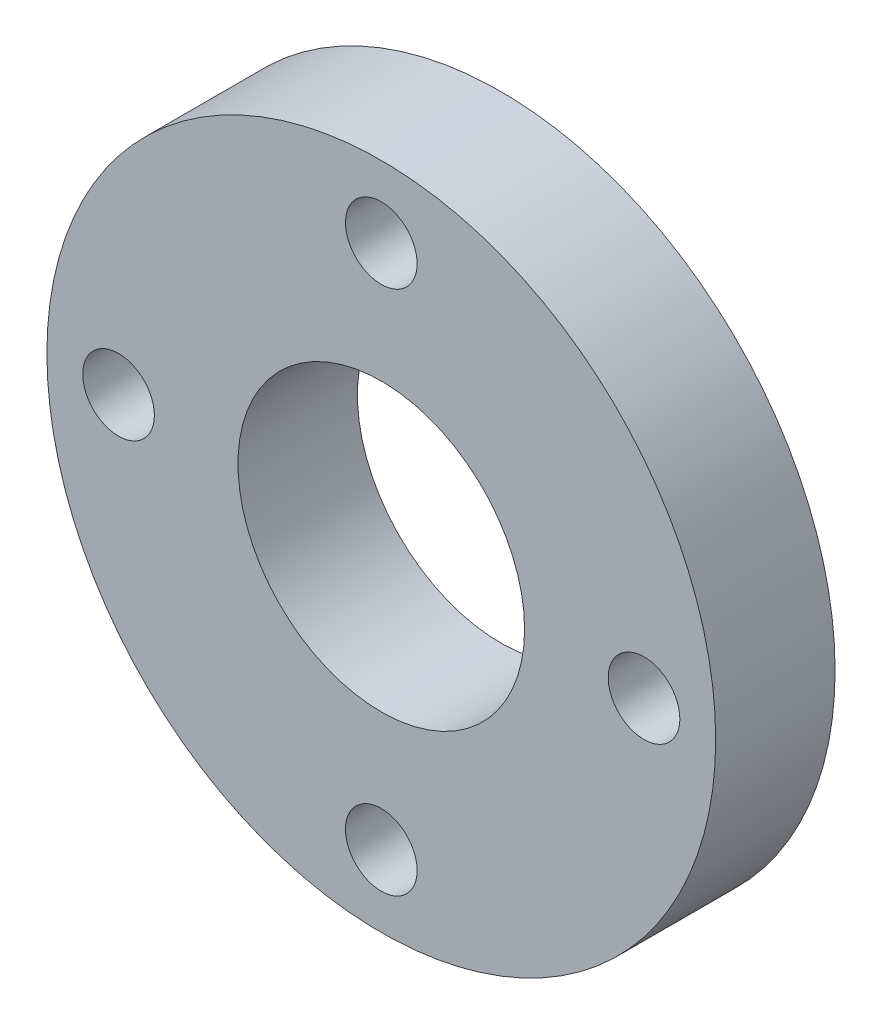
from build123d import *

# Parameters (mm, degrees)
CROQUIS1_R              = 14
CROQUIS1_R_2            = 1.5
CROQUIS1_R_3            = 6
SALIENTE_EXTRUIR1_DEPTH = 5


with BuildPart() as part:
    # Croquis1 → Saliente-Extruir1 (new body)
    with BuildSketch(Plane.XY):
        Circle(CROQUIS1_R)
        with Locations((11, 0)):
            Circle(CROQUIS1_R_2, mode=Mode.SUBTRACT)
        with Locations((0, -11)):
            Circle(CROQUIS1_R_2, mode=Mode.SUBTRACT)
        with Locations((-11, 0)):
            Circle(CROQUIS1_R_2, mode=Mode.SUBTRACT)
        with Locations((0, 11)):
            Circle(CROQUIS1_R_2, mode=Mode.SUBTRACT)
        Circle(CROQUIS1_R_3, mode=Mode.SUBTRACT)
    extrude(amount=SALIENTE_EXTRUIR1_DEPTH)


solid = part.part
